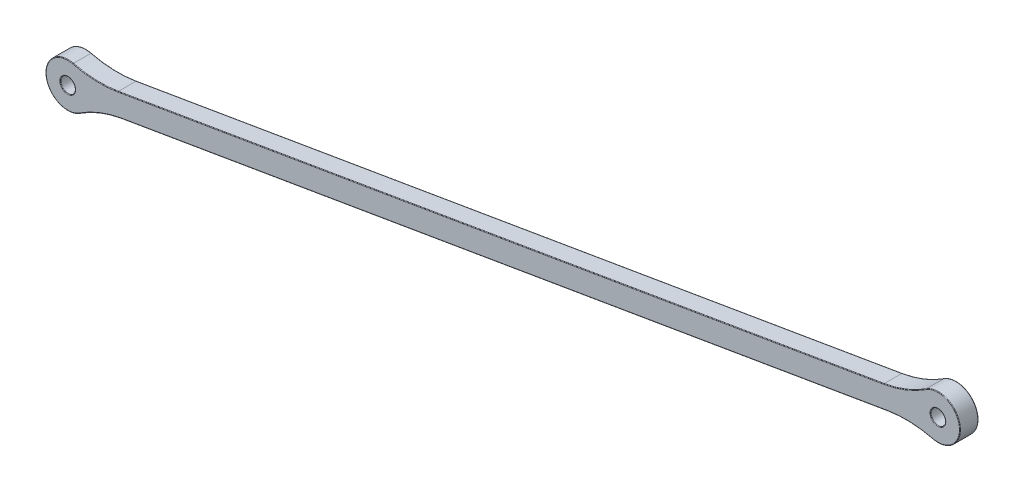
from build123d import *

# Parameters (mm, degrees)
SKETCH1_R           = 2
BOSS_EXTRUDE1_DEPTH = 5
FILLET1_R           = 30
FILLET2_R           = 0.15


with BuildPart() as part:
    # Sketch1 → Boss-Extrude1 (new body)
    with BuildSketch(Plane.XY):
        with BuildLine():
            ThreePointArc((-303.354663584, 266.924296542), (-313.891870914, 262.09510502), (-302.35178592, 261.008703893))
            Line((-302.35178592, 261.008703893), (-75.974186977, 299.386775376))
            ThreePointArc((-75.974186977, 299.386775376), (-65.436979647, 304.215966898), (-76.97706464, 305.302368025))
            Line((-76.97706464, 305.302368025), (-303.354663584, 266.924296542))
        make_face()
        with Locations((-307.976278265, 263.097982683)):
            Circle(SKETCH1_R, mode=Mode.SUBTRACT)
        with Locations((-71.352572296, 303.213089234)):
            Circle(SKETCH1_R, mode=Mode.SUBTRACT)
    extrude(amount=-BOSS_EXTRUDE1_DEPTH)

    # Fillet1
    fillet1_edges = [part.edges().sort_by_distance(p)[0] for p in [
        (-303.354663584, 266.924296542, -2.5),
        (-76.97706464, 305.302368025, -2.5),
        (-75.974186977, 299.386775376, -2.5),
        (-302.35178592, 261.008703893, -2.5),
    ]]
    fillet(fillet1_edges, radius=FILLET1_R)

    # Fillet2
    fillet2_edges = [part.edges().sort_by_distance(p)[0] for p in [
        (-313.891870914, 262.09510502, 0),
        (-313.891870914, 262.09510502, -5),
        (-189.162986448, 280.197739634, 0),
        (-189.162986448, 280.197739634, -5),
        (-65.436979647, 304.215966898, 0),
        (-309.976278265, 263.097982683, -5),
        (-65.436979647, 304.215966898, -5),
        (-190.165864112, 286.113332283, 0),
        (-190.165864112, 286.113332283, -5),
        (-299.221745151, 260.898681077, 0),
        (-299.221745151, 260.898681077, -5),
        (-73.352572296, 303.213089234, -5),
        (-78.893071958, 298.251270772, 0),
        (-78.893071958, 298.251270772, -5),
        (-80.107105409, 305.41239084, 0),
        (-80.107105409, 305.41239084, -5),
        (-300.435778603, 268.059801145, 0),
        (-300.435778603, 268.059801145, -5),
        (-73.352572296, 303.213089234, 0),
        (-309.976278265, 263.097982683, 0),
    ]]
    fillet(fillet2_edges, radius=FILLET2_R)


solid = part.part
